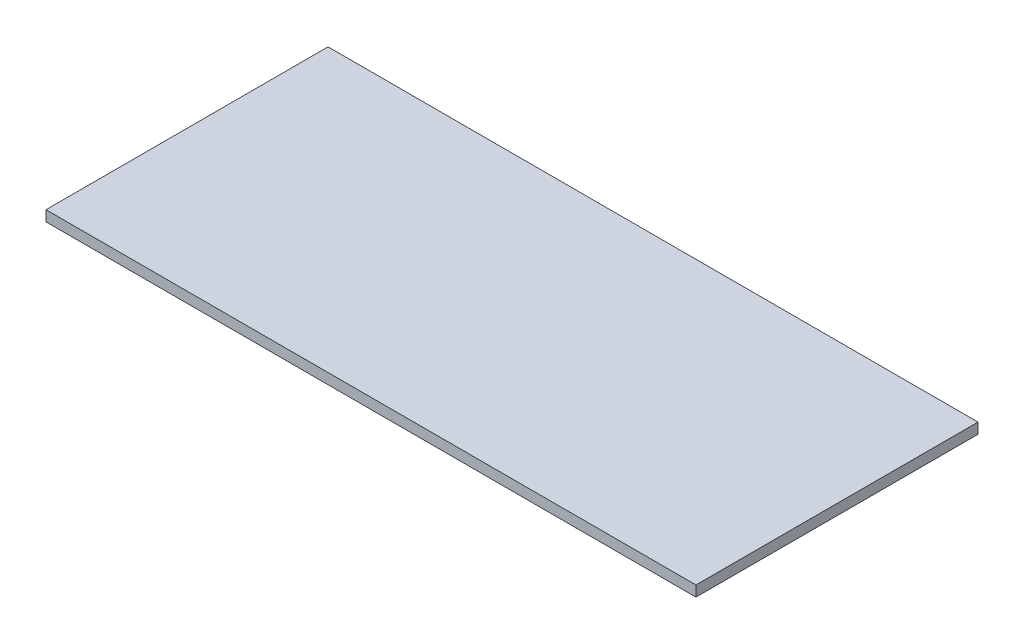
from build123d import *

# Parameters (mm, degrees)
SKETCH1_W           = 103.0732
SKETCH1_H           = 44.7294
BOSS_EXTRUDE1_DEPTH = 1.6764


with BuildPart() as part:
    # Sketch1 → Boss-Extrude1 (new body)
    with BuildSketch(Plane(origin=(0, 0, 0), x_dir=(1, 0, 0), z_dir=(0, 1, 0))):
        Rectangle(SKETCH1_W, SKETCH1_H)
    extrude(amount=BOSS_EXTRUDE1_DEPTH)


solid = part.part
